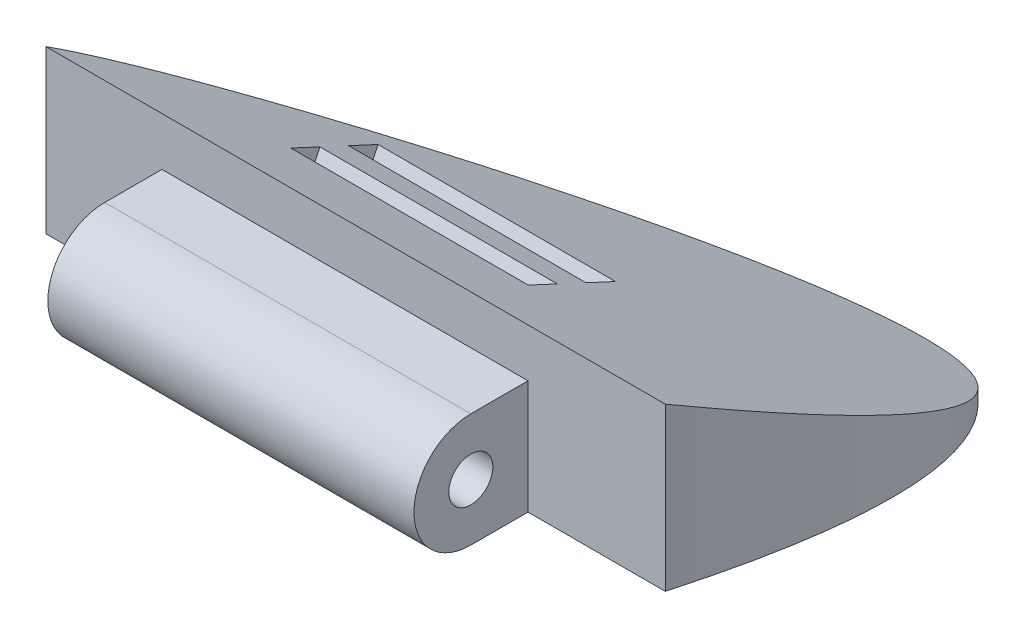
from build123d import *

# Parameters (mm, degrees)
BOSS_EXTRUDE1_DEPTH     = 12.7
SKETCH2_W               = 19.216952518
SKETCH2_H               = 6.005297662
CUT_EXTRUDE1_DEPTH      = 2.54
SKETCH3_W               = 18.322345719
SKETCH3_H               = 4.189551825
SKETCH3_R               = 1.155216028
CUT_EXTRUDE2_DEPTH      = 11.684
CUT_EXTRUDE2_DEPTH_BACK = 26.924
SKETCH4_W               = 6.230536122
SKETCH4_H               = 1.706386664
SKETCH4_W_2             = 6.230536121
SKETCH4_H_2             = 1.682353049
CUT_EXTRUDE4_DEPTH      = 3.81
SKETCH5_W               = 12.461072243
SKETCH5_H               = 1.883415491
CUT_EXTRUDE5_DEPTH      = 2.54
SKETCH6_W               = 6.43751361
SKETCH6_H               = 1.686706137
SKETCH6_H_2             = 1.657293844
CUT_EXTRUDE6_DEPTH      = 1.0000001
CUT_EXTRUDE6_DEPTH_BACK = 3.81


with BuildPart() as part:
    # Sketch1 → Boss-Extrude1 (new body)
    with BuildSketch(Plane(origin=(0, 0, 0), x_dir=(1, 0, 0), z_dir=(0, 1, 0))):
        with BuildLine():
            Line((0, 0), (19.216952518, 0))
            Line((19.216952518, 0), (19.216952518, 6.005297662))
            Line((19.216952518, 6.005297662), (26.423309712, 6.005297662))
            add(Edge.make_bspline(
                [(26.423309712, 6.005297662), (36.55952446, 42.663140535), (-2.021004002, 14.397041287), (-6.085368297, 6.005297662)],
                knots=[0, 0, 0, 0, 1, 1, 1, 1], degree=3))
            Line((-6.085368297, 6.005297662), (0, 6.005297662))
            Line((0, 6.005297662), (0, 0))
        make_face()
    extrude(amount=BOSS_EXTRUDE1_DEPTH)

    # Sketch2 → Cut-Extrude1 (cut)
    with BuildSketch(Plane(origin=(0, 12.7, 0), x_dir=(1, 0, 0), z_dir=(0, 1, 0))):
        with Locations((9.608476259, 3.002648831)):
            Rectangle(SKETCH2_W, SKETCH2_H)
    extrude(amount=-CUT_EXTRUDE1_DEPTH, mode=Mode.SUBTRACT)

    # Sketch3 → Cut-Extrude2 (cut, two sides)
    with BuildSketch(Plane(origin=(19.216952518, 0, 0), x_dir=(0, 0, -1), z_dir=(1, 0, 0))) as cut_extrude2_sk:
        Polygon((24.327643381, 12.7), (6.005297662, 12.7), (24.327643381, 4.189551825), align=None)
        with Locations((15.166470522, 2.094775913)):
            Rectangle(SKETCH3_W, SKETCH3_H)
        Polygon((3.002648831, 4.189551825), (0, 4.189551825), (0, 0), (6.005297662, 0), (6.005297662, 4.189551825), align=None)
        with BuildLine():
            Line((3.002648831, 10.16), (0, 10.16))
            Line((0, 10.16), (0, 4.189551825))
            Line((0, 4.189551825), (3.002648831, 4.189551825))
            ThreePointArc((3.002648831, 4.189551825), (0.017424743, 7.174775912), (3.002648831, 10.16))
        make_face()
        with Locations((3.002648831, 7.174775912)):
            Circle(SKETCH3_R)
    extrude(amount=CUT_EXTRUDE2_DEPTH, mode=Mode.SUBTRACT)
    extrude(cut_extrude2_sk.sketch, amount=-CUT_EXTRUDE2_DEPTH_BACK, mode=Mode.SUBTRACT)

    # Sketch4 → Cut-Extrude4 (cut)
    with BuildSketch(Plane(origin=(0, 12.740629014, -5.917826495), x_dir=(1, 0, 0), z_dir=(0, 0.906940046, -0.421259722))):
        with Locations((6.493208198, 8.028748928)):
            Rectangle(SKETCH4_W, SKETCH4_H)
        with Locations((12.72374432, 8.028748928)):
            Rectangle(SKETCH4_W_2, SKETCH4_H)
        with Locations((12.72374432, 4.676059638)):
            Rectangle(SKETCH4_W_2, SKETCH4_H_2)
        with Locations((6.493208198, 4.676059638)):
            Rectangle(SKETCH4_W, SKETCH4_H_2)
    extrude(amount=-CUT_EXTRUDE4_DEPTH, mode=Mode.SUBTRACT)

    # Sketch5 → Cut-Extrude5 (cut)
    with BuildSketch(Plane(origin=(0, -2.32418937, -5.003802419), x_dir=(1, 0, 0), z_dir=(0, 0.421259722, 0.906940046))):
        with Locations((9.608476259, 11.179636351)):
            Rectangle(SKETCH5_W, SKETCH5_H)
    extrude(amount=-CUT_EXTRUDE5_DEPTH, mode=Mode.SUBTRACT)

    # Sketch6 → Cut-Extrude6 (cut, two sides)
    with BuildSketch(Plane(origin=(0, 4.189551825, 0), x_dir=(-1, 0, 0), z_dir=(0, -1, 0))) as cut_extrude6_sk:
        with Locations((-6.389719454, 9.230258043)):
            Rectangle(SKETCH6_W, SKETCH6_H)
        with Locations((-12.827233064, 9.230258043)):
            Rectangle(SKETCH6_W, SKETCH6_H)
        with Locations((-12.827233064, 12.681510307)):
            Rectangle(SKETCH6_W, SKETCH6_H_2)
        with Locations((-6.389719454, 12.681510307)):
            Rectangle(SKETCH6_W, SKETCH6_H_2)
    extrude(amount=CUT_EXTRUDE6_DEPTH, mode=Mode.SUBTRACT)
    extrude(cut_extrude6_sk.sketch, amount=-CUT_EXTRUDE6_DEPTH_BACK, mode=Mode.SUBTRACT)


solid = part.part
